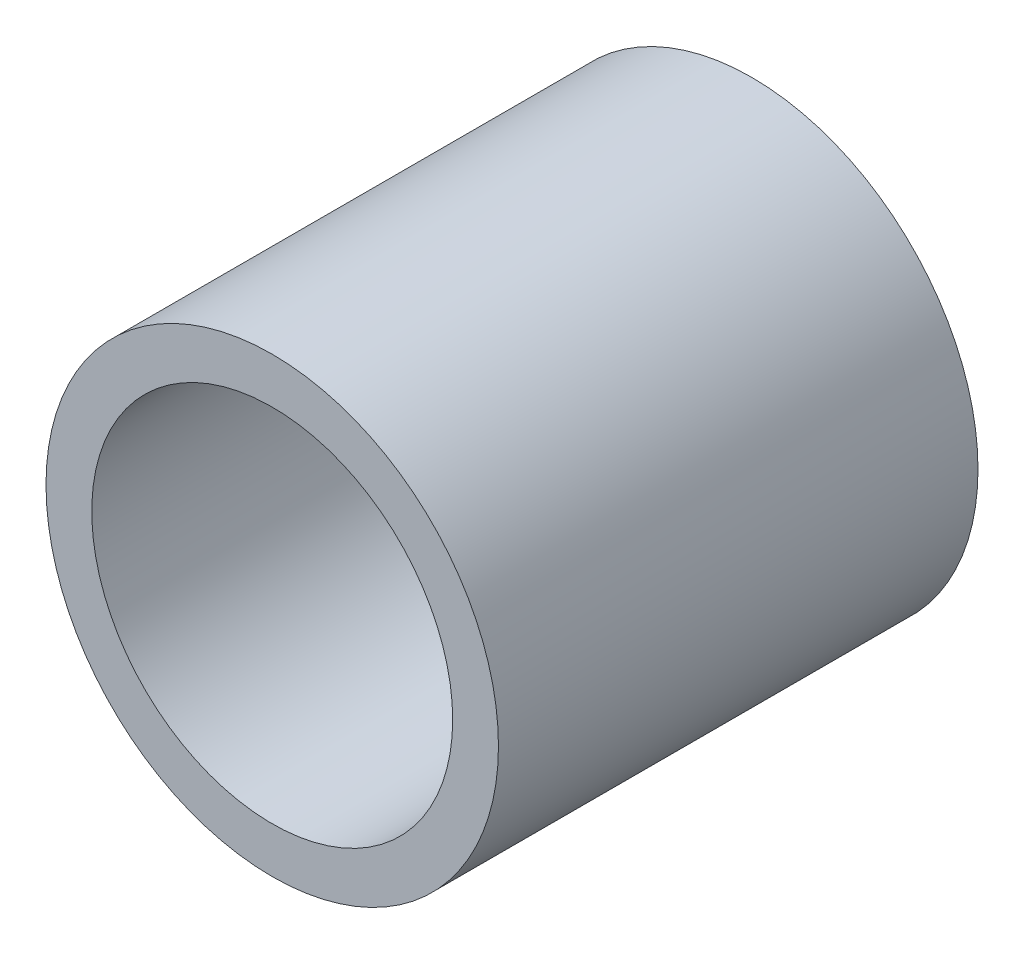
from build123d import *

# Parameters (mm, degrees)
SKETCH1_R                  = 16.7005
SKETCH1_R_2                = 13.3223
MIEMBRO_ESTRUCTURAL1_DEPTH = 35.4


with BuildPart() as part:
    # Sketch1 → Miembro estructural1 (new body)
    with BuildSketch(Plane(origin=(0, 0, 0), x_dir=(0, -1, 0), z_dir=(0, 0, 1))):
        Circle(SKETCH1_R)
        Circle(SKETCH1_R_2, mode=Mode.SUBTRACT)
    extrude(amount=MIEMBRO_ESTRUCTURAL1_DEPTH)


solid = part.part
